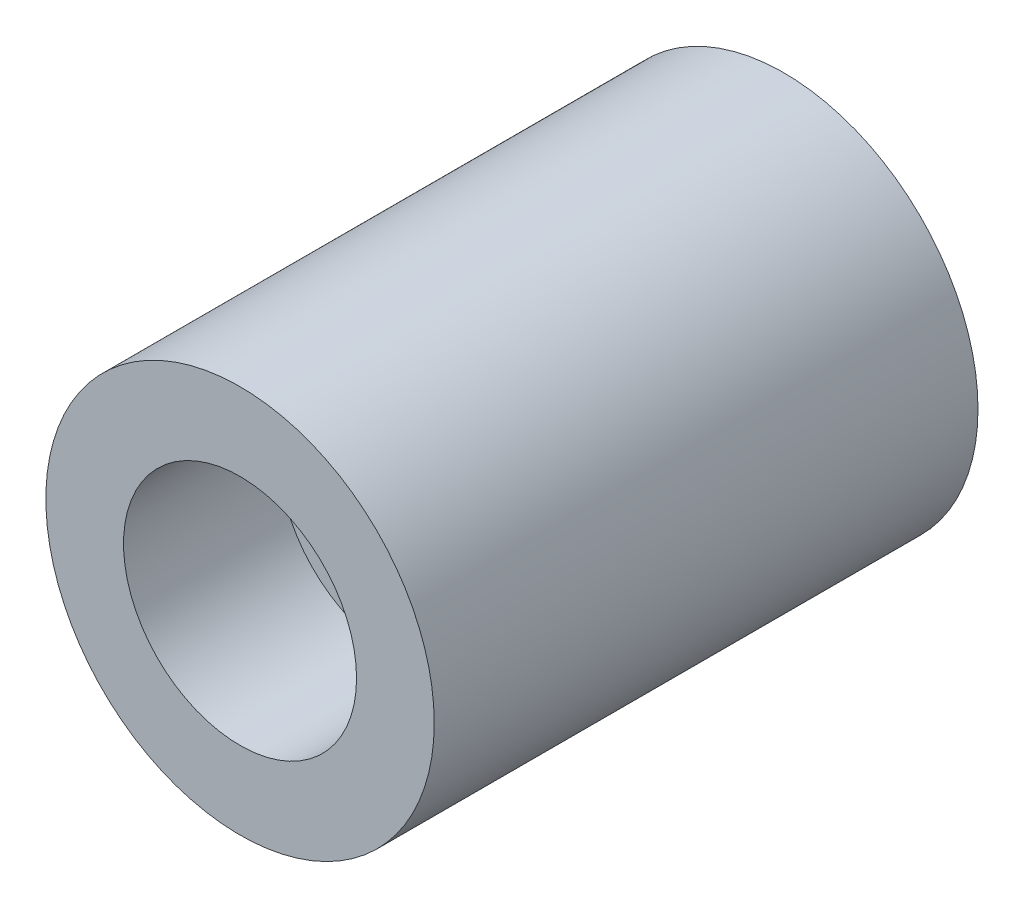
from build123d import *


with BuildPart() as part:
    # Sketch1 → Revolve1 (revolve)
    with BuildSketch(Plane(origin=(0, 0, 0), x_dir=(1, 0, 0), z_dir=(0, 1, 0))):
        Polygon((0, 3556), (1270, 3556), (1270, 0), (762, 0), (762, 1016), (254, 1016), (254, 3048), (0, 3048), align=None)
    revolve(axis=Axis((0, 0, 0), (0, 0, -1)))


solid = part.part
